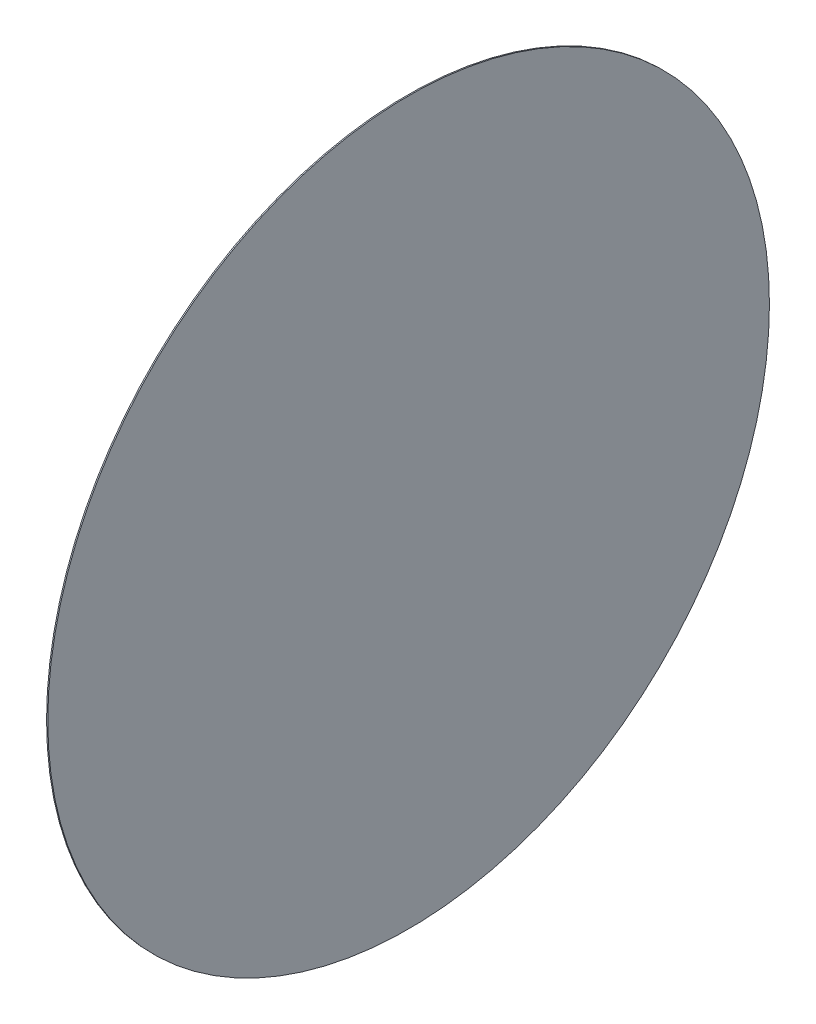
from build123d import *

# Parameters (mm, degrees)
SKETCH_1_W = 0.03
SKETCH_1_H = 9


with BuildPart() as part:
    # 草图1 → 旋转2 (revolve)
    with BuildSketch(Plane.XY, mode=Mode.PRIVATE) as revolve_2_sk:
        with Locations((0.015, 4.5)):
            Rectangle(SKETCH_1_W, SKETCH_1_H)
    revolve(revolve_2_sk.sketch.rotate(Axis((0, 0, 0), (1, 0, 0)), 90), axis=Axis((0, 0, 0), (1, 0, 0)))  # turned: the seam where the file's is


solid = part.part
